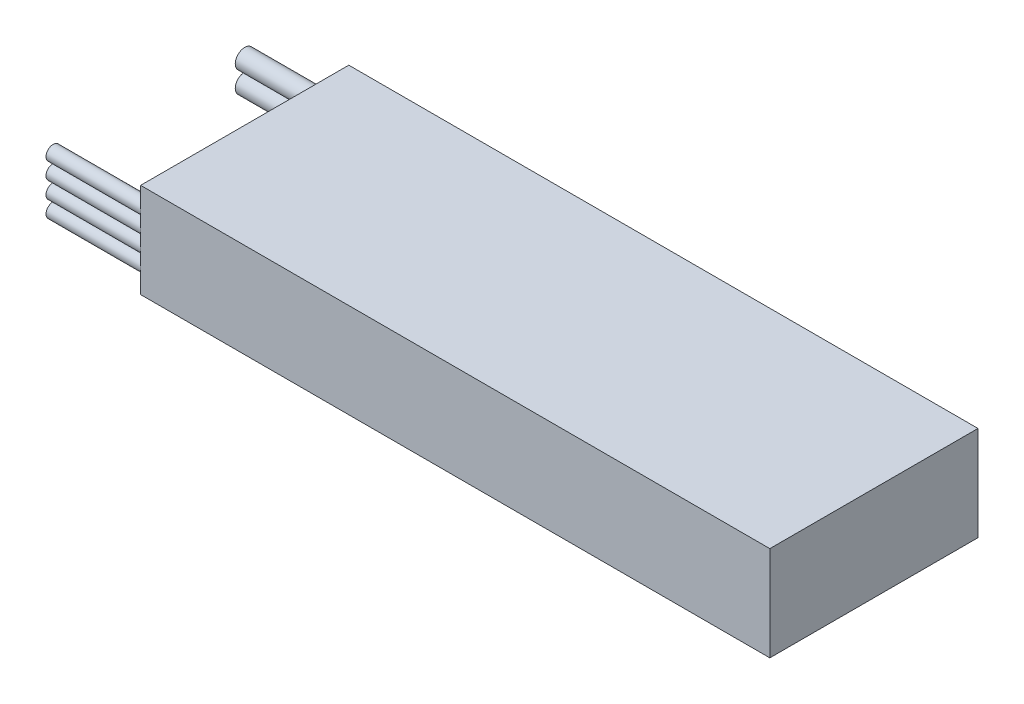
from build123d import *

# Parameters (mm, degrees)
SKETCH1_W           = 133
SKETCH1_H           = 44
BOSS_EXTRUDE1_DEPTH = 20
BOSS_EXTRUDE3_DEPTH = 20


with BuildPart() as part:
    # Sketch1 → Boss-Extrude1 (new body)
    with BuildSketch(Plane(origin=(0, 0, 0), x_dir=(1, 0, 0), z_dir=(0, 1, 0))):
        Rectangle(SKETCH1_W, SKETCH1_H)
    extrude(amount=BOSS_EXTRUDE1_DEPTH)

    # Sketch2 → Boss-Extrude3 (add)
    with BuildSketch(Plane.ZY.offset(66.5)):
        with BuildLine():
            ThreePointArc((-18, 12.25), (-18.775155536, 13.831061681), (-20.499756038, 14.186554647))
            Line((-20.499756038, 14.186554647), (-20, 12.25))
            Line((-20, 12.25), (-20, 10.25))
            ThreePointArc((-20, 10.25), (-18.585786438, 10.835786438), (-18, 12.25))
        make_face()
        with BuildLine():
            Line((-20, 12.25), (-20.499756038, 14.186554647))
            ThreePointArc((-20.499756038, 14.186554647), (-21.984075263, 11.998116391), (-20, 10.25))
            Line((-20, 10.25), (-20, 12.25))
        make_face()
        with BuildLine():
            ThreePointArc((-18, 7.75), (-18.585786438, 9.164213562), (-20, 9.75))
            Line((-20, 9.75), (-20, 7.75))
            Line((-20, 7.75), (-20.499756038, 5.813445353))
            ThreePointArc((-20.499756038, 5.813445353), (-18.775155536, 6.168938319), (-18, 7.75))
        make_face()
        with BuildLine():
            Line((-20, 7.75), (-20, 9.75))
            ThreePointArc((-20, 9.75), (-21.984075263, 8.001883609), (-20.499756038, 5.813445353))
            Line((-20.499756038, 5.813445353), (-20, 7.75))
        make_face()
        with BuildLine():
            ThreePointArc((22, 15.25), (21.709864781, 16.136694542), (20.951697052, 16.680373998))
            Line((20.951697052, 16.680373998), (20.5, 15.25))
            Line((20.5, 15.25), (20.5, 13.75))
            ThreePointArc((20.5, 13.75), (21.560660172, 14.189339828), (22, 15.25))
        make_face()
        with BuildLine():
            Line((20.5, 15.25), (20.951697052, 16.680373998))
            ThreePointArc((20.951697052, 16.680373998), (19.017508685, 15.478515868), (20.5, 13.75))
            Line((20.5, 13.75), (20.5, 15.25))
        make_face()
        with BuildLine():
            ThreePointArc((22, 11.75), (21.560660172, 12.810660172), (20.5, 13.25))
            Line((20.5, 13.25), (20.5, 11.75))
            Line((20.5, 11.75), (20.5, 10.25))
            ThreePointArc((20.5, 10.25), (21.560660172, 10.689339828), (22, 11.75))
        make_face()
        with BuildLine():
            Line((20.5, 11.75), (20.5, 13.25))
            ThreePointArc((20.5, 13.25), (19, 11.75), (20.5, 10.25))
            Line((20.5, 10.25), (20.5, 11.75))
        make_face()
        with BuildLine():
            ThreePointArc((22, 8.25), (21.560660172, 9.310660172), (20.5, 9.75))
            Line((20.5, 9.75), (20.5, 8.25))
            Line((20.5, 8.25), (20.5, 6.75))
            ThreePointArc((20.5, 6.75), (21.560660172, 7.189339828), (22, 8.25))
        make_face()
        with BuildLine():
            Line((20.5, 8.25), (20.5, 9.75))
            ThreePointArc((20.5, 9.75), (19, 8.25), (20.5, 6.75))
            Line((20.5, 6.75), (20.5, 8.25))
        make_face()
        with BuildLine():
            ThreePointArc((22, 4.75), (21.560660172, 5.810660172), (20.5, 6.25))
            Line((20.5, 6.25), (20.5, 4.75))
            Line((20.5, 4.75), (20.951697052, 3.319626002))
            ThreePointArc((20.951697052, 3.319626002), (21.709864781, 3.863305458), (22, 4.75))
        make_face()
        with BuildLine():
            Line((20.5, 4.75), (20.5, 6.25))
            ThreePointArc((20.5, 6.25), (19.017508685, 4.521484132), (20.951697052, 3.319626002))
            Line((20.951697052, 3.319626002), (20.5, 4.75))
        make_face()
    extrude(amount=BOSS_EXTRUDE3_DEPTH)


solid = part.part
